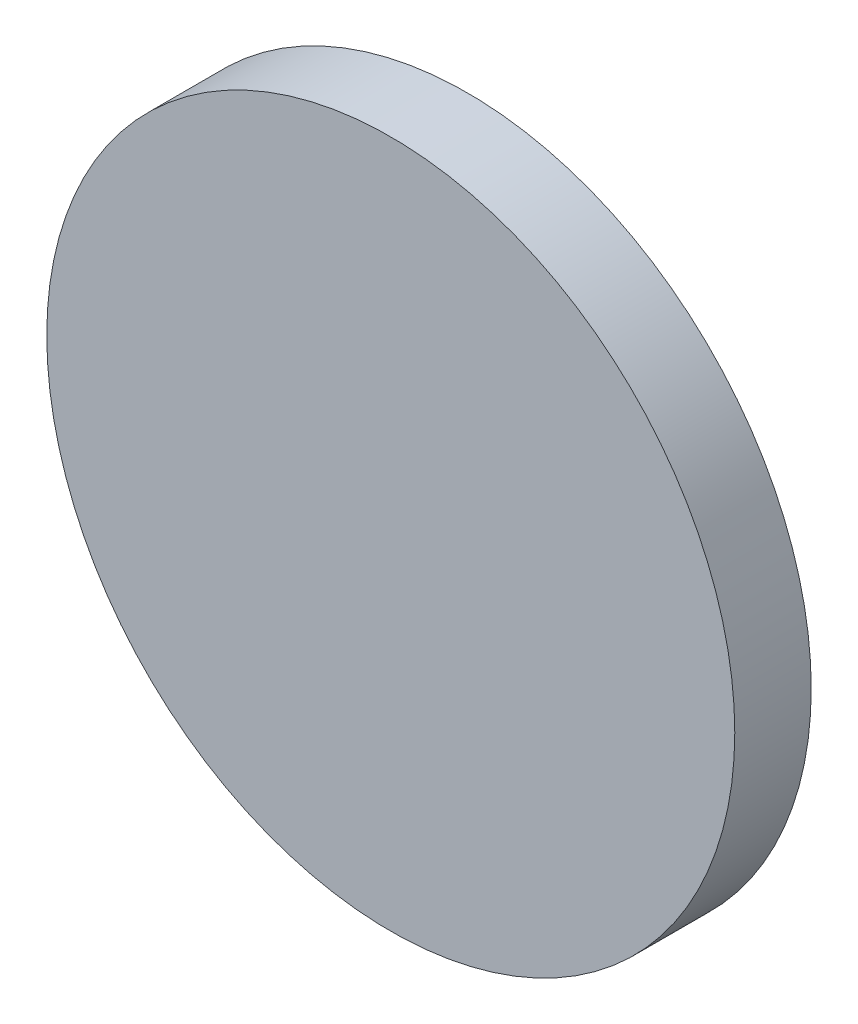
from build123d import *

# Parameters (mm, degrees)
SKETCH1_R           = 114.3
BOSS_EXTRUDE1_DEPTH = 25.4


with BuildPart() as part:
    # Sketch1 → Boss-Extrude1 (new body)
    with BuildSketch(Plane.XY):
        Circle(SKETCH1_R)
    extrude(amount=BOSS_EXTRUDE1_DEPTH)


solid = part.part
